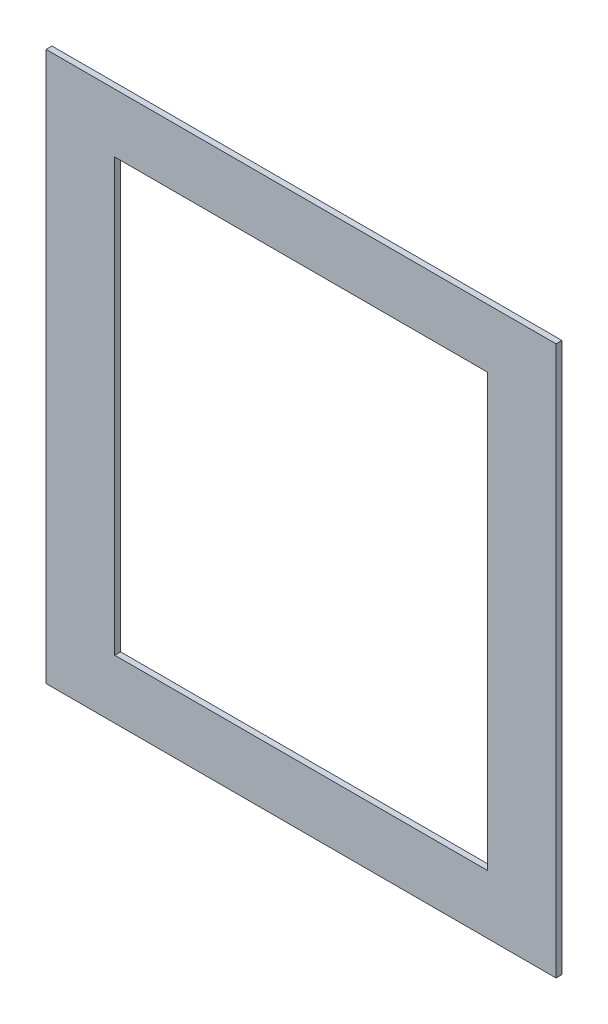
from build123d import *

# Parameters (mm, degrees)
SKETCH_1_W      = 520
SKETCH_1_H      = 560
SKETCH_1_W_2    = 380
SKETCH_1_H_2    = 440
EXTRUDE_1_DEPTH = 6


with BuildPart() as part:
    # Эскиз1 → Бобышка-Вытянуть1 (new body)
    with BuildSketch(Plane.XY):
        with Locations((202.327917168, 260.464227839)):
            Rectangle(SKETCH_1_W, SKETCH_1_H)
        with Locations((202.327917168, 260.464227839)):
            Rectangle(SKETCH_1_W_2, SKETCH_1_H_2, mode=Mode.SUBTRACT)
    extrude(amount=EXTRUDE_1_DEPTH)


solid = part.part
